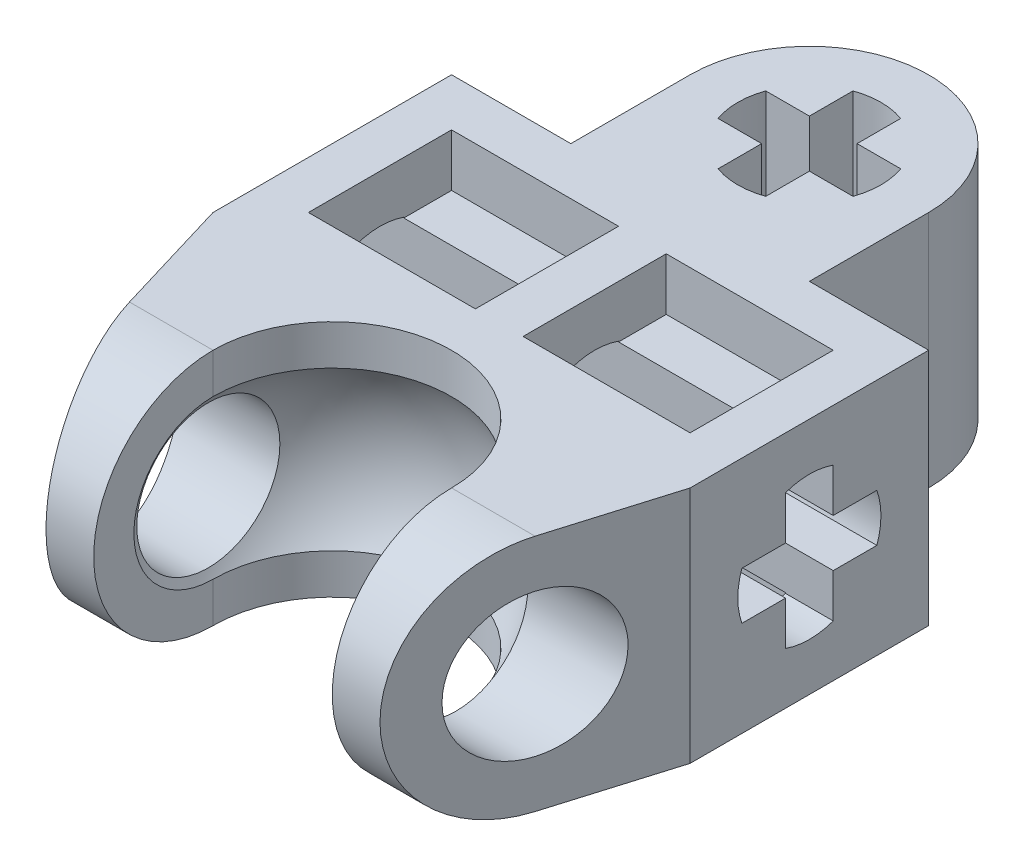
from build123d import *

# Parameters (mm, degrees)
BOSS_EXTRUDE1_DEPTH     = 5
SKETCH3_R               = 1.5
CUT_EXTRUDE1_DEPTH      = 10
CUT_EXTRUDE2_REACH      = 7
CUT_EXTRUDE4_DEPTH      = 10
CUT_EXTRUDE5_DEPTH      = 10
CUT_EXTRUDE5_DEPTH_BACK = 10
CUT_EXTRUDE6_DEPTH      = 10
SKETCH8_W               = 3.5
SKETCH8_H               = 3
CUT_EXTRUDE13_DEPTH     = 1.1
SKETCH9_W               = 3.5
SKETCH9_H               = 3
CUT_EXTRUDE14_DEPTH     = 1.1


with BuildPart() as part:
    # Sketch1 → Boss-Extrude1 (new body)
    with BuildSketch(Plane(origin=(0, 0, 0), x_dir=(1, 0, 0), z_dir=(0, 1, 0))):
        Polygon((-5, 5), (-5, -5), (5, -5), (5, 5), (2.5, 5), (1e-09, 5), (-2.5, 5), align=None)
        with BuildLine():
            Line((-2.5, 7.5), (-2.5, 5))
            Line((-2.5, 5), (1e-09, 5))
            ThreePointArc((1e-09, 5), (-1.767766953, 5.732233047), (-2.5, 7.5))
        make_face()
        with BuildLine():
            Line((1e-09, 5), (2.5, 5))
            Line((2.5, 5), (2.5, 7.5))
            ThreePointArc((2.5, 7.5), (1.767766953, 5.732233047), (1e-09, 5))
        make_face()
        with BuildLine():
            ThreePointArc((2.5, 7.5), (0, 10), (-2.5, 7.5))
            Line((-2.5, 7.5), (-1.5, 7.5))
            Line((-1.5, 7.499999998), (-1.5, 8))
            Line((-1.5, 8), (-1.414213562, 8))
            ThreePointArc((-1.414213562, 8), (-1.060660172, 8.560660172), (-0.5, 8.914213562))
            Line((-0.5, 8.914213562), (-0.5, 9))
            Line((-0.5, 9), (-1.7e-08, 9))
            Line((-1.7e-08, 9), (0.5, 9))
            Line((0.5, 9), (0.5, 8.914213562))
            ThreePointArc((0.5, 8.914213562), (1.060660172, 8.560660172), (1.414213562, 8))
            Line((1.414213562, 8), (1.5, 8))
            Line((1.5, 8), (1.5, 7.5))
            Line((1.5, 7.5), (2.5, 7.5))
        make_face()
        with BuildLine():
            ThreePointArc((-2.5, 7.5), (-1.767766953, 5.732233047), (1e-09, 5))
            ThreePointArc((1e-09, 5), (1.767766953, 5.732233047), (2.5, 7.5))
            Line((2.5, 7.5), (1.5, 7.5))
            Line((1.5, 7.5), (1.5, 7))
            Line((1.5, 7), (1.414213562, 7))
            ThreePointArc((1.414213562, 7), (1.060660172, 6.439339828), (0.5, 6.085786438))
            Line((0.5, 6.085786438), (0.5, 6))
            Line((0.5, 6), (0, 6))
            Line((0, 6), (-0.5, 6))
            Line((-0.5, 6), (-0.5, 6.085786438))
            ThreePointArc((-0.5, 6.085786438), (-1.060660172, 6.439339828), (-1.414213562, 7))
            Line((-1.414213562, 7), (-1.5, 7))
            Line((-1.5, 7), (-1.5, 7.499999998))
            Line((-1.5, 7.5), (-2.5, 7.5))
        make_face()
        with BuildLine():
            Line((0.5, 6), (0.5, 6.085786438))
            ThreePointArc((0.5, 6.085786438), (0.253652968, 6.021602161), (0, 6))
            Line((0, 6), (0.5, 6))
        make_face()
        with BuildLine():
            Line((-0.5, 7), (-1.414213562, 7))
            ThreePointArc((-1.414213562, 7), (-1.060660172, 6.439339828), (-0.5, 6.085786438))
            Line((-0.5, 6.085786438), (-0.5, 7))
        make_face()
        with BuildLine():
            ThreePointArc((0.5, 6.085786438), (1.060660172, 6.439339828), (1.414213562, 7))
            Line((1.414213562, 7), (0.5, 7))
            Line((0.5, 7), (0.5, 6.085786438))
        make_face()
        with BuildLine():
            Line((0.5, 8), (1.414213562, 8))
            ThreePointArc((1.414213562, 8), (1.060660172, 8.560660172), (0.5, 8.914213562))
            Line((0.5, 8.914213562), (0.5, 8))
        make_face()
        with BuildLine():
            ThreePointArc((-0.5, 8.914213562), (-1.060660172, 8.560660172), (-1.414213562, 8))
            Line((-1.414213562, 8), (-0.5, 8))
            Line((-0.5, 8), (-0.5, 8.914213562))
        make_face()
        with BuildLine():
            Line((-0.5, 9), (-0.5, 8.914213562))
            ThreePointArc((-0.5, 8.914213562), (-0.253652976, 8.978397838), (-1.7e-08, 9))
            Line((-1.7e-08, 9), (-0.5, 9))
        make_face()
        with BuildLine():
            ThreePointArc((-1.7e-08, 9), (0.25365296, 8.978397841), (0.5, 8.914213562))
            Line((0.5, 8.914213562), (0.5, 9))
            Line((0.5, 9), (-1.7e-08, 9))
        make_face()
        with BuildLine():
            ThreePointArc((-1.414213562, 7), (-1.478397839, 7.246347031), (-1.5, 7.499999998))
            Line((-1.5, 7.499999998), (-1.5, 7))
            Line((-1.5, 7), (-1.414213562, 7))
        make_face()
        with BuildLine():
            ThreePointArc((0, 6), (-0.253652968, 6.021602161), (-0.5, 6.085786438))
            Line((-0.5, 6.085786438), (-0.5, 6))
            Line((-0.5, 6), (0, 6))
        make_face()
        with BuildLine():
            Line((-1.5, 8), (-1.5, 7.499999998))
            ThreePointArc((-1.5, 7.499999998), (-1.47839784, 7.753652967), (-1.414213562, 8))
            Line((-1.414213562, 8), (-1.5, 8))
        make_face()
        with BuildLine():
            Line((1.5, 7), (1.5, 7.5))
            ThreePointArc((1.5, 7.5), (1.478397839, 7.246347032), (1.414213562, 7))
            Line((1.414213562, 7), (1.5, 7))
        make_face()
        with BuildLine():
            ThreePointArc((1.414213562, 8), (1.478397839, 7.753652968), (1.5, 7.5))
            Line((1.5, 7.5), (1.5, 8))
            Line((1.5, 8), (1.414213562, 8))
        make_face()
    extrude(amount=BOSS_EXTRUDE1_DEPTH)

    # Sketch2 → Cut-Revolve3 (revolve, cut)
    with BuildSketch(Plane(origin=(0, 0, 0), x_dir=(0, 0, -1), z_dir=(1, 0, 0))):
        with BuildLine():
            Line((-2.5, 5.5), (-2.5, -0.5))
            ThreePointArc((-2.5, -0.5), (0.5, 2.5), (-2.5, 5.5))
        make_face()
    revolve(axis=Axis((0, 5.5, 2.5), (0, -1, 0)), mode=Mode.SUBTRACT)

    # Sketch3 → Cut-Extrude1 (cut)
    with BuildSketch(Plane(origin=(5, 0, 0), x_dir=(0, 0, -1), z_dir=(1, 0, 0))):
        with Locations((-2.5, 2.5)):
            Circle(SKETCH3_R)
    extrude(amount=-CUT_EXTRUDE1_DEPTH, mode=Mode.SUBTRACT)

    # Sketch4 → Cut-Extrude2 (cut, up to next)
    with BuildSketch(Plane(origin=(0, 5, 0), x_dir=(1, 0, 0), z_dir=(0, 1, 0)), mode=Mode.PRIVATE) as cut_extrude2_sk1:
        Polygon((-5, 0), (-3.5, -5), (-5, -5), align=None)
    cut_extrude2_tool1 = extrude(cut_extrude2_sk1.sketch, amount=-CUT_EXTRUDE2_REACH, mode=Mode.PRIVATE) & part.part
    add(cut_extrude2_tool1.solids().sort_by_distance((-4.5, 5, 3.333333))[0], mode=Mode.SUBTRACT)
    # Sketch4 → Cut-Extrude2 (cut, up to next)
    with BuildSketch(Plane(origin=(0, 5, 0), x_dir=(1, 0, 0), z_dir=(0, 1, 0)), mode=Mode.PRIVATE) as cut_extrude2_sk2:
        Polygon((5, 0), (3.5, -5), (5, -5), align=None)
    cut_extrude2_tool2 = extrude(cut_extrude2_sk2.sketch, amount=-CUT_EXTRUDE2_REACH, mode=Mode.PRIVATE) & part.part
    add(cut_extrude2_tool2.solids().sort_by_distance((4.5, 5, 3.333333))[0], mode=Mode.SUBTRACT)

    # Sketch5 → Cut-Extrude4 (cut)
    with BuildSketch(Plane(origin=(0, 5, 0), x_dir=(1, 0, 0), z_dir=(0, 1, 0))):
        with BuildLine():
            ThreePointArc((-1.658312395, -2.5), (0, -0.841687605), (1.658312395, -2.5))
            Line((1.658312395, -2.5), (2.5, -2.5))
            ThreePointArc((2.5, -2.5), (0, 0), (-2.5, -2.5))
            Line((-2.5, -2.5), (-1.658312395, -2.5))
        make_face()
        with BuildLine():
            Line((2.5, -2.5), (1.658312395, -2.5))
            ThreePointArc((1.658312395, -2.5), (0, -4.158312395), (-1.658312395, -2.5))
            Line((-1.658312395, -2.5), (-2.5, -2.5))
            ThreePointArc((-2.5, -2.5), (-1.767766953, -4.267766953), (0, -5))
            ThreePointArc((0, -5), (1.767766953, -4.267766953), (2.5, -2.5))
        make_face()
        with BuildLine():
            Line((2.5, -5), (2.5, -2.5))
            ThreePointArc((2.5, -2.5), (1.767766953, -4.267766953), (0, -5))
            Line((0, -5), (2.5, -5))
        make_face()
        with BuildLine():
            ThreePointArc((0, -5), (-1.767766953, -4.267766953), (-2.5, -2.5))
            Line((-2.5, -2.5), (-2.5, -5))
            Line((-2.5, -5), (0, -5))
        make_face()
    extrude(amount=-CUT_EXTRUDE4_DEPTH, mode=Mode.SUBTRACT)

    # Sketch6 → Cut-Extrude5 (cut, two sides)
    with BuildSketch(Plane(origin=(-2.5, 0, 0), x_dir=(0, 0, -1), z_dir=(1, 0, 0))) as cut_extrude5_sk:
        with BuildLine():
            ThreePointArc((-5, 2.5), (-4.267766953, 4.267766953), (-2.5, 5))
            Line((-2.5, 5), (-5, 5))
            Line((-5, 5), (-5, 2.5))
        make_face()
        with BuildLine():
            Line((-5, 0), (-2.5, 0))
            ThreePointArc((-2.5, 0), (-4.267766953, 0.732233047), (-5, 2.5))
            Line((-5, 2.5), (-5, 0))
        make_face()
    extrude(amount=CUT_EXTRUDE5_DEPTH, mode=Mode.SUBTRACT)
    extrude(cut_extrude5_sk.sketch, amount=-CUT_EXTRUDE5_DEPTH_BACK, mode=Mode.SUBTRACT)

    # Sketch7 → Cut-Extrude6 (cut)
    with BuildSketch(Plane.ZY.offset(5)):
        with BuildLine():
            Line((-3.914213562, 2), (-3, 2))
            Line((-3, 2), (-3, 3))
            Line((-3, 3), (-3.914213562, 3))
            ThreePointArc((-3.914213562, 3), (-3.978397839, 2.753652968), (-4, 2.5))
            ThreePointArc((-4, 2.5), (-3.978397839, 2.246347032), (-3.914213562, 2))
        make_face()
        Polygon((-3, 3), (-3, 2), (-2, 3), align=None)
        with BuildLine():
            Line((-3, 3), (-2, 3))
            Line((-2, 3), (-2, 3.914213562))
            ThreePointArc((-2, 3.914213562), (-2.246347032, 3.978397839), (-2.5, 4))
            ThreePointArc((-2.5, 4), (-2.753652968, 3.978397839), (-3, 3.914213562))
            Line((-3, 3.914213562), (-3, 3))
        make_face()
        Polygon((-2, 3), (-3, 2), (-2, 2), align=None)
        with BuildLine():
            Line((-1.085786438, 3), (-2, 3))
            Line((-2, 3), (-2, 2))
            Line((-2, 2), (-1.085786438, 2))
            ThreePointArc((-1.085786438, 2), (-1.021602161, 2.246347032), (-1, 2.5))
            ThreePointArc((-1, 2.5), (-1.021602161, 2.753652968), (-1.085786438, 3))
        make_face()
        with BuildLine():
            Line((-2, 2), (-3, 2))
            Line((-3, 2), (-3, 1.085786438))
            ThreePointArc((-3, 1.085786438), (-2.753652968, 1.021602161), (-2.5, 1))
            ThreePointArc((-2.5, 1), (-2.246347032, 1.021602161), (-2, 1.085786438))
            Line((-2, 1.085786438), (-2, 2))
        make_face()
    extrude(amount=-CUT_EXTRUDE6_DEPTH, mode=Mode.SUBTRACT)

    # Sketch8 → Cut-Extrude13 (cut)
    with BuildSketch(Plane(origin=(0, 5, 0), x_dir=(1, 0, 0), z_dir=(0, 1, 0))):
        with Locations((2.25, 2.5)):
            Rectangle(SKETCH8_W, SKETCH8_H)
        with Locations((-2.25, 2.5)):
            Rectangle(SKETCH8_W, SKETCH8_H)
    extrude(amount=-CUT_EXTRUDE13_DEPTH, mode=Mode.SUBTRACT)

    # Sketch9 → Cut-Extrude14 (cut)
    with BuildSketch(Plane(origin=(0, 0, 0), x_dir=(-1, 0, 0), z_dir=(0, -1, 0))):
        with Locations((-2.25, 2.5)):
            Rectangle(SKETCH9_W, SKETCH9_H)
        with Locations((2.25, 2.5)):
            Rectangle(SKETCH9_W, SKETCH9_H)
    extrude(amount=-CUT_EXTRUDE14_DEPTH, mode=Mode.SUBTRACT)


solid = part.part
